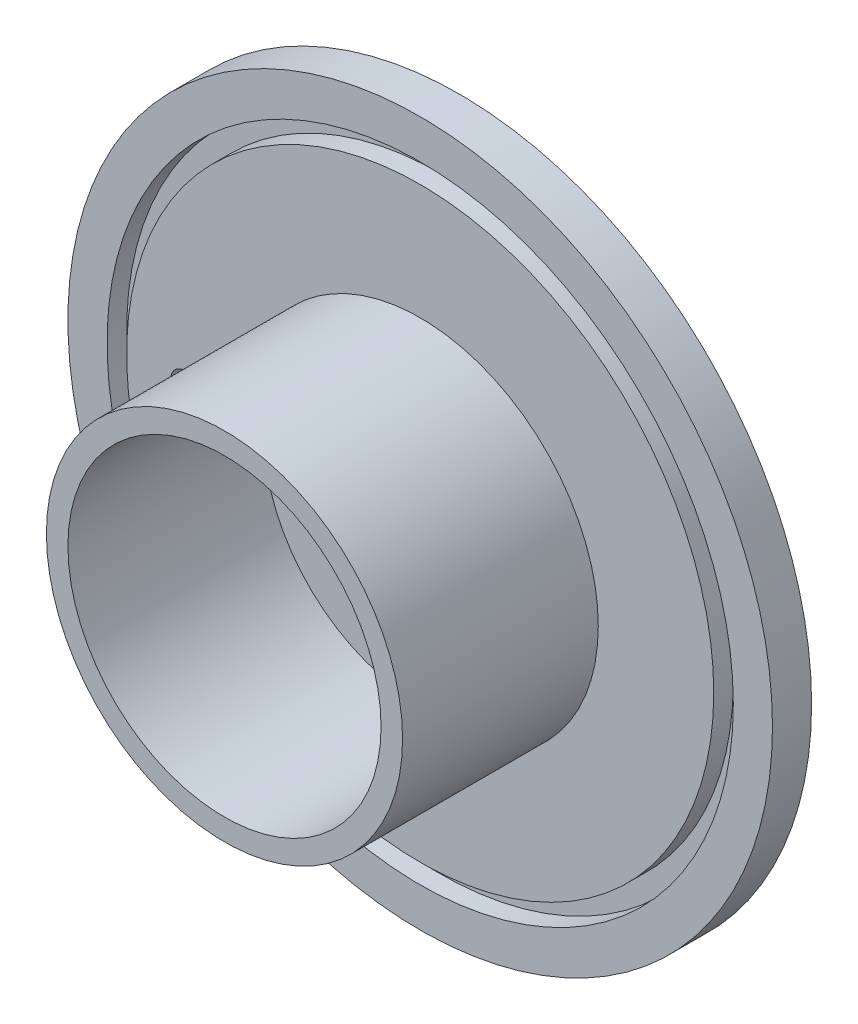
from build123d import *

# Parameters (mm, degrees)
SKETCH1_R        = 57.15
SKETCH1_R_2      = 50.8
EXTRUDE3_DEPTH   = 6.35
SKETCH1_R_3      = 47.625
SKETCH1_R_4      = 28.8925
SKETCH1_R_5      = 2.38125
EXTRUDE3_2_DEPTH = 6.35
SKETCH1_R_6      = 25.4
EXTRUDE3_3_DEPTH = 6.35
SKETCH1_8_R      = 50.8
SKETCH1_8_R_2    = 47.625
EXTRUDE4_DEPTH   = 3.175
SKETCH1_9_R      = 28.8925
SKETCH1_9_R_2    = 25.4
EXTRUDE5_DEPTH   = 38.1


with BuildPart() as part:
    # Sketch1 → Extrude3 (new body)
    with BuildSketch(Plane.XY):
        Circle(SKETCH1_R)
        Circle(SKETCH1_R_2, mode=Mode.SUBTRACT)
    extrude(amount=EXTRUDE3_DEPTH)



with BuildPart() as body_2:
    # Sketch1 → Extrude3 2 (new body)
    with BuildSketch(Plane.XY):
        Circle(SKETCH1_R_3)
        Circle(SKETCH1_R_4, mode=Mode.SUBTRACT)
        with Locations((-38.1, 0)):
            Circle(SKETCH1_R_5, mode=Mode.SUBTRACT)
    extrude(amount=EXTRUDE3_2_DEPTH)


with BuildPart() as body_3:
    # Sketch1 → Extrude3 3 (new body)
    with BuildSketch(Plane.XY):
        Circle(SKETCH1_R_6)
        Circle(SKETCH1_R_5, mode=Mode.SUBTRACT)
    extrude(amount=EXTRUDE3_3_DEPTH)


with BuildPart() as part_1:
    add(part.part)

    add(body_2.part)  # Extrude4 merges body 2
    # Sketch1_8 → Extrude4 (add)
    with BuildSketch(Plane.XY):
        Circle(SKETCH1_8_R)
        Circle(SKETCH1_8_R_2, mode=Mode.SUBTRACT)
    extrude(amount=EXTRUDE4_DEPTH)


    add(body_3.part)  # Extrude5 merges body 3
    # Sketch1_9 → Extrude5 (add)
    with BuildSketch(Plane.XY):
        Circle(SKETCH1_9_R)
        Circle(SKETCH1_9_R_2, mode=Mode.SUBTRACT)
    extrude(amount=EXTRUDE5_DEPTH)


solid = part_1.part
